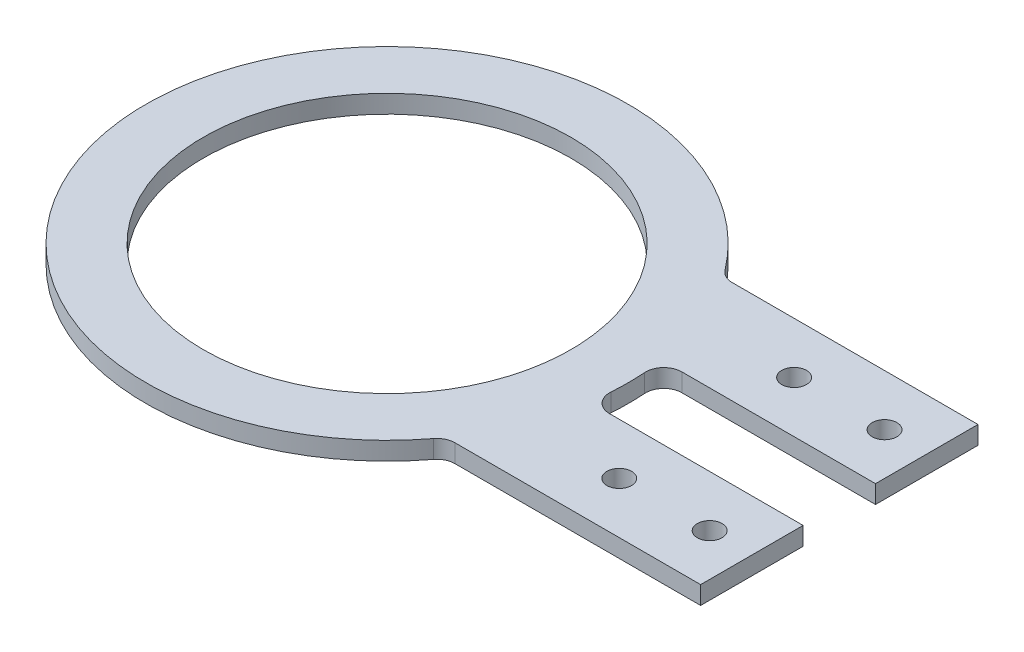
from build123d import *

# Parameters (mm, degrees)
SKETCH1_R           = 40
SKETCH1_R_2         = 30.5
BOSS_EXTRUDE1_DEPTH = 3
SKETCH2_W           = 42.273863656
SKETCH2_H           = 17
BOSS_EXTRUDE2_DEPTH = 3
SKETCH3_R           = 2.05
CUT_EXTRUDE1_DEPTH  = 4
FILLET1_R           = 3


with BuildPart() as part:
    # Sketch1 → Boss-Extrude1 (new body)
    with BuildSketch(Plane(origin=(0, 0, 0), x_dir=(1, 0, 0), z_dir=(0, 1, 0))):
        Circle(SKETCH1_R)
        Circle(SKETCH1_R_2, mode=Mode.SUBTRACT)
    extrude(amount=BOSS_EXTRUDE1_DEPTH)

    # Sketch2 → Boss-Extrude2 (add)
    with BuildSketch(Plane(origin=(0, 3, 0), x_dir=(1, 0, 0), z_dir=(0, 1, 0))):
        with Locations((53.863068172, 14.5)):
            Rectangle(SKETCH2_W, SKETCH2_H)
        with Locations((53.863068172, -14.5)):
            Rectangle(SKETCH2_W, SKETCH2_H)
    extrude(amount=-BOSS_EXTRUDE2_DEPTH)

    # Sketch3 → Cut-Extrude1 (cut, through all)
    with BuildSketch(Plane(origin=(0, 3, 0), x_dir=(1, 0, 0), z_dir=(0, 1, 0))):
        with Locations((53, 14.5)):
            Circle(SKETCH3_R)
        with Locations((68, 14.5)):
            Circle(SKETCH3_R)
        with Locations((53, -14.5)):
            Circle(SKETCH3_R)
        with Locations((68, -14.5)):
            Circle(SKETCH3_R)
    extrude(amount=-CUT_EXTRUDE1_DEPTH, mode=Mode.SUBTRACT)

    # Fillet1
    fillet1_edges = [part.edges().sort_by_distance(p)[0] for p in [
        (39.547439867, 1.5, -6),
        (32.726136344, 1.5, -23),
        (39.547439867, 1.5, 6),
        (32.726136344, 1.5, 23),
    ]]
    fillet(fillet1_edges, radius=FILLET1_R)


solid = part.part
